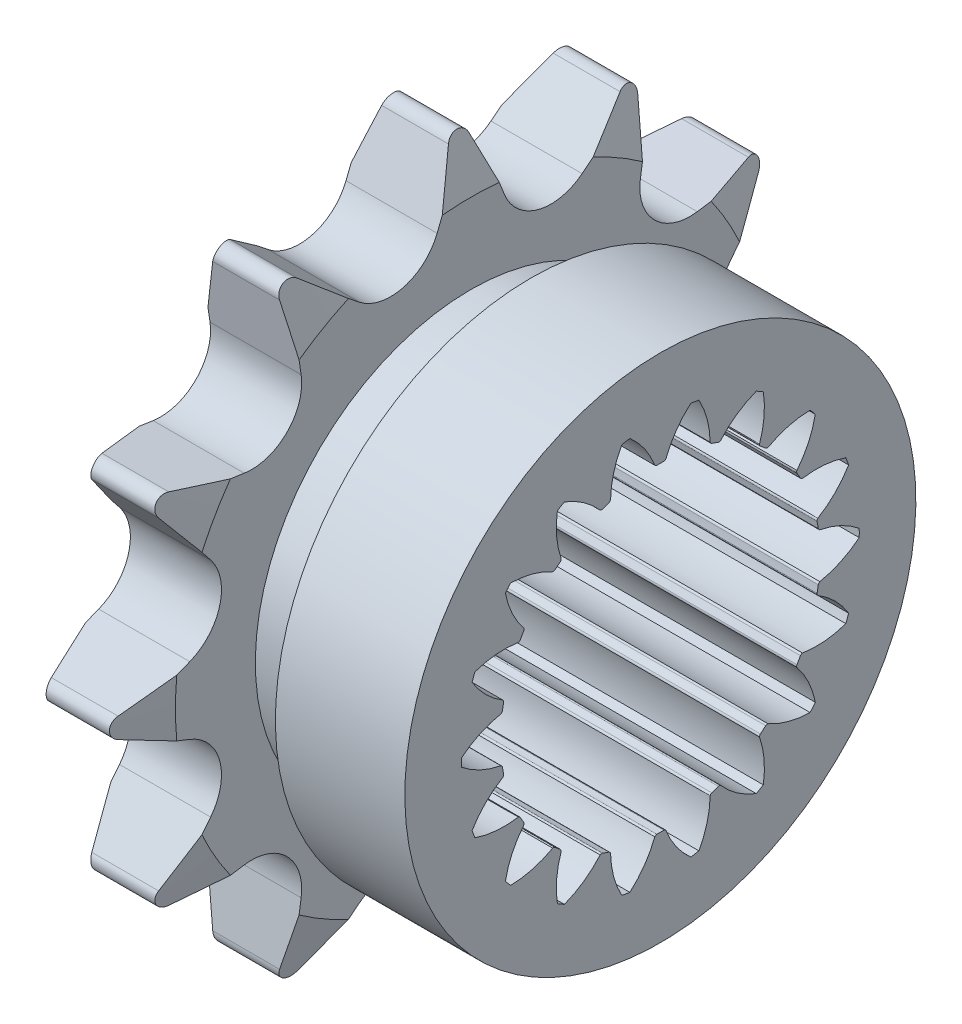
from build123d import *

# Parameters (mm, degrees)
SKETCH13_W         = 22.225
SKETCH13_H         = 27.5082
CUT_EXTRUDE1_DEPTH = 7.2136
CIRPATTERN1_COUNT  = 12
SKETCH15_W         = 127
SKETCH15_H         = 22.5171
SKETCH16_W         = 4.7625
SKETCH16_H         = 3.175
CUT_EXTRUDE2_DEPTH = 23.225


with BuildPart() as part:
    # Sketch13 → Revolve1 (revolve)
    with BuildSketch(Plane.XY):
        with Locations((11.1125, 13.7541)):
            Rectangle(SKETCH13_W, SKETCH13_H)
    revolve(axis=Axis((0, 0, 0), (-1, 0, 0)))

    # Sketch6 → Cut-Extrude1 (cut)
    with BuildSketch(Plane(origin=(0, -16.51, 0), x_dir=(0, 0, -1), z_dir=(1, 0, 0))):
        with BuildLine():
            Line((-0.805715716, 43.469749783), (-2.663822441, 38.756002806))
            ThreePointArc((-2.663822441, 38.756002806), (-5.324614334, 36.381731224), (-8.816063498, 37.107514783))
            Line((-8.816063498, 37.107514783), (-12.782104613, 40.260686049))
            ThreePointArc((-12.782104613, 40.260686049), (-13.256994885, 40.44645554), (-13.7541, 40.332800012))
            ThreePointArc((-13.7541, 40.332800012), (-7.119646056, 43.080880815), (0, 44.0182))
            ThreePointArc((0, 44.0182), (-0.487333422, 43.868076017), (-0.805715716, 43.469749783))
        make_face()
    cut_extrude1 = extrude(amount=CUT_EXTRUDE1_DEPTH, mode=Mode.SUBTRACT)

    # CirPattern1: Cut-Extrude1 ×12 about axis
    cirpattern1_axis = Axis((-63.015770793, 0, 0), (1, 0, 0))
    for i in range(1, CIRPATTERN1_COUNT):
        add(cut_extrude1.rotate(cirpattern1_axis, i * 360 / CIRPATTERN1_COUNT), mode=Mode.SUBTRACT)

    # Sketch15 → hub Cut-Revolve3 (revolve, cut)
    with BuildSketch(Plane.XY):
        with Locations((70.7136, 31.48965)):
            Rectangle(SKETCH15_W, SKETCH15_H)
    revolve(axis=Axis((0, 0, 0), (-1, 0, 0)), mode=Mode.SUBTRACT)

    # Sketch4 → Teeth Chamfer (revolve, cut)
    with BuildSketch(Plane.XY):
        Polygon((0, 27.5082), (1.104501883, 27.5082), (0, 23.386142857), align=None)
        Polygon((7.2136, 27.5082), (6.109098117, 27.5082), (7.2136, 23.386142857), align=None)
    revolve(axis=Axis((0, 0, 0), (-1, 0, 0)), mode=Mode.SUBTRACT)

    # Sketch16 → Recess (revolve, cut)
    with BuildSketch(Plane.XY):
        with Locations((9.59485, 18.6436)):
            Rectangle(SKETCH16_W, SKETCH16_H)
    revolve(axis=Axis((0, 0, 0), (-1, 0, 0)), mode=Mode.SUBTRACT)

    # Sketch36 → Cut-Extrude2 (cut, through all)
    with BuildSketch(Plane.ZY):
        with BuildLine():
            ThreePointArc((-4.7729934, 11.8201419), (-6.061029895, 12.982143528), (-7.592553624, 13.796834183))
            ThreePointArc((-7.592553624, 13.796834183), (-7.873999984, 13.638168068), (-8.152132052, 13.473761428))
            ThreePointArc((-8.152132052, 13.473761428), (-8.212351117, 11.740077645), (-7.850046439, 10.043604504))
            ThreePointArc((-7.850046439, 10.043604504), (-7.86626214, 9.947703548), (-7.918307228, 9.865537551))
            ThreePointArc((-7.918307228, 9.865537551), (-8.13141367, 9.690641477), (-8.340658225, 9.511142985))
            ThreePointArc((-8.340658225, 9.511142985), (-8.430613472, 9.474156555), (-8.527873304, 9.474840233))
            ThreePointArc((-8.527873304, 9.474840233), (-10.135659657, 10.126230162), (-11.853461818, 10.367976993))
            ThreePointArc((-11.853461818, 10.367976993), (-12.063667879, 10.122619291), (-12.268796147, 9.873000815))
            ThreePointArc((-12.268796147, 9.873000815), (-11.732428783, 8.223274824), (-10.811745764, 6.753027031))
            ThreePointArc((-10.811745764, 6.753027031), (-10.794183479, 6.657363513), (-10.814987438, 6.562352263))
            ThreePointArc((-10.814987438, 6.562352263), (-10.95542401, 6.325117018), (-11.090657474, 6.084877757))
            ThreePointArc((-11.090657474, 6.084877757), (-11.162537651, 6.019355375), (-11.254165829, 5.986733001))
            ThreePointArc((-11.254165829, 5.986733001), (-12.987779277, 6.048943991), (-14.684667578, 5.688588763))
            ThreePointArc((-14.684667578, 5.688588763), (-14.798279386, 5.386133234), (-14.905662359, 5.081410594))
            ThreePointArc((-14.905662359, 5.081410594), (-13.837402385, 3.714623697), (-12.469388985, 2.647934833))
            ThreePointArc((-12.469388985, 2.647934833), (-12.420166986, 2.564047187), (-12.407220551, 2.467650443))
            ThreePointArc((-12.407220551, 2.467650443), (-12.458048528, 2.196690097), (-12.50295975, 1.924686467))
            ThreePointArc((-12.50295975, 1.924686467), (-12.548095048, 1.8385311), (-12.623039862, 1.776537414))
            ThreePointArc((-12.623039862, 1.776537414), (-14.273381038, 1.242065902), (-15.744685706, 0.323072774))
            ThreePointArc((-15.744685706, 0.323072774), (-15.748, 1.8e-08), (-15.744685707, -0.323072738))
            ThreePointArc((-15.744685707, -0.323072738), (-14.273381041, -1.24206587), (-12.623039866, -1.776537385))
            ThreePointArc((-12.623039866, -1.776537385), (-12.548095052, -1.838531072), (-12.502959755, -1.924686439))
            ThreePointArc((-12.502959755, -1.924686439), (-12.458048533, -2.196690069), (-12.407220557, -2.467650415))
            ThreePointArc((-12.407220557, -2.467650415), (-12.420166992, -2.564047159), (-12.469388991, -2.647934805))
            ThreePointArc((-12.469388991, -2.647934805), (-13.837402393, -3.714623666), (-14.905662371, -5.08141056))
            ThreePointArc((-14.905662371, -5.08141056), (-14.798279398, -5.3861332), (-14.684667591, -5.68858873))
            ThreePointArc((-14.684667591, -5.68858873), (-12.987779291, -6.048943962), (-11.254165843, -5.986732975))
            ThreePointArc((-11.254165843, -5.986732975), (-11.162537665, -6.01935535), (-11.090657488, -6.084877731))
            ThreePointArc((-11.090657488, -6.084877731), (-10.955424024, -6.325116993), (-10.814987453, -6.562352239))
            ThreePointArc((-10.814987453, -6.562352239), (-10.794183495, -6.657363489), (-10.811745779, -6.753027006))
            ThreePointArc((-10.811745779, -6.753027006), (-11.732428801, -8.223274797), (-12.26879617, -9.873000787))
            ThreePointArc((-12.26879617, -9.873000787), (-12.063667902, -10.122619264), (-11.853461841, -10.367976966))
            ThreePointArc((-11.853461841, -10.367976966), (-10.13565968, -10.126230139), (-8.527873325, -9.474840214))
            ThreePointArc((-8.527873325, -9.474840214), (-8.430613493, -9.474156536), (-8.340658247, -9.511142966))
            ThreePointArc((-8.340658247, -9.511142966), (-8.131413692, -9.690641459), (-7.91830725, -9.865537533))
            ThreePointArc((-7.91830725, -9.865537533), (-7.866262163, -9.94770353), (-7.850046462, -10.043604486))
            ThreePointArc((-7.850046462, -10.043604486), (-8.212351144, -11.740077626), (-8.152132082, -13.473761409))
            ThreePointArc((-8.152132082, -13.473761409), (-7.874000016, -13.63816805), (-7.592553655, -13.796834166))
            ThreePointArc((-7.592553655, -13.796834166), (-6.061029924, -12.982143514), (-4.772993427, -11.820141889))
            ThreePointArc((-4.772993427, -11.820141889), (-4.681832912, -11.78623462), (-4.584652527, -11.79022399))
            ThreePointArc((-4.584652527, -11.79022399), (-4.326634863, -11.887331546), (-4.066562331, -11.9787934))
            ThreePointArc((-4.066562331, -11.9787934), (-3.98955352, -12.038203713), (-3.941515687, -12.122775038))
            ThreePointArc((-3.941515687, -12.122775038), (-3.701742737, -13.840853828), (-3.052200553, -15.449387554))
            ThreePointArc((-3.052200553, -15.449387554), (-2.73461152, -15.508752491), (-2.415871444, -15.561589545))
            ThreePointArc((-2.415871444, -15.561589545), (-1.255350509, -14.272218786), (-0.442420079, -12.739760006))
            ThreePointArc((-0.442420079, -12.739760006), (-0.368354185, -12.676718863), (-0.27567005, -12.647229995))
            ThreePointArc((-0.27567005, -12.647229995), (-1.4e-08, -12.65023401), (0.275670021, -12.647229995))
            ThreePointArc((0.275670021, -12.647229995), (0.368354156, -12.676718864), (0.44242005, -12.739760007))
            ThreePointArc((0.44242005, -12.739760007), (1.255350476, -14.272218789), (2.415871408, -15.561589551))
            ThreePointArc((2.415871408, -15.561589551), (2.734611484, -15.508752498), (3.052200518, -15.449387561))
            ThreePointArc((3.052200518, -15.449387561), (3.701742705, -13.840853836), (3.941515659, -12.122775047))
            ThreePointArc((3.941515659, -12.122775047), (3.989553493, -12.038203723), (4.066562304, -11.978793409))
            ThreePointArc((4.066562304, -11.978793409), (4.326634836, -11.887331556), (4.5846525, -11.790224))
            ThreePointArc((4.5846525, -11.790224), (4.681832885, -11.786234631), (4.7729934, -11.8201419))
            ThreePointArc((4.7729934, -11.8201419), (6.061029895, -12.982143528), (7.592553624, -13.796834183))
            ThreePointArc((7.592553624, -13.796834183), (7.873999984, -13.638168068), (8.152132052, -13.473761428))
            ThreePointArc((8.152132052, -13.473761428), (8.212351117, -11.740077645), (7.850046439, -10.043604504))
            ThreePointArc((7.850046439, -10.043604504), (7.86626214, -9.947703548), (7.918307228, -9.865537551))
            ThreePointArc((7.918307228, -9.865537551), (8.13141367, -9.690641477), (8.340658225, -9.511142985))
            ThreePointArc((8.340658225, -9.511142985), (8.430613472, -9.474156555), (8.527873304, -9.474840233))
            ThreePointArc((8.527873304, -9.474840233), (10.135659657, -10.126230162), (11.853461818, -10.367976993))
            ThreePointArc((11.853461818, -10.367976993), (12.063667879, -10.122619291), (12.268796147, -9.873000815))
            ThreePointArc((12.268796147, -9.873000815), (11.732428783, -8.223274824), (10.811745764, -6.753027031))
            ThreePointArc((10.811745764, -6.753027031), (10.794183479, -6.657363513), (10.814987438, -6.562352263))
            ThreePointArc((10.814987438, -6.562352263), (10.95542401, -6.325117018), (11.090657474, -6.084877757))
            ThreePointArc((11.090657474, -6.084877757), (11.162537651, -6.019355375), (11.254165829, -5.986733001))
            ThreePointArc((11.254165829, -5.986733001), (12.987779277, -6.048943991), (14.684667578, -5.688588763))
            ThreePointArc((14.684667578, -5.688588763), (14.798279386, -5.386133234), (14.905662359, -5.081410594))
            ThreePointArc((14.905662359, -5.081410594), (13.837402385, -3.714623697), (12.469388985, -2.647934833))
            ThreePointArc((12.469388985, -2.647934833), (12.420166986, -2.564047187), (12.407220551, -2.467650443))
            ThreePointArc((12.407220551, -2.467650443), (12.458048528, -2.196690097), (12.50295975, -1.924686467))
            ThreePointArc((12.50295975, -1.924686467), (12.548095048, -1.8385311), (12.623039862, -1.776537414))
            ThreePointArc((12.623039862, -1.776537414), (14.273381038, -1.242065902), (15.744685706, -0.323072774))
            ThreePointArc((15.744685706, -0.323072774), (15.748, -1.8e-08), (15.744685707, 0.323072738))
            ThreePointArc((15.744685707, 0.323072738), (14.273381041, 1.24206587), (12.623039866, 1.776537385))
            ThreePointArc((12.623039866, 1.776537385), (12.548095052, 1.838531072), (12.502959755, 1.924686439))
            ThreePointArc((12.502959755, 1.924686439), (12.458048533, 2.196690069), (12.407220557, 2.467650415))
            ThreePointArc((12.407220557, 2.467650415), (12.420166992, 2.564047159), (12.469388991, 2.647934805))
            ThreePointArc((12.469388991, 2.647934805), (13.837402393, 3.714623666), (14.905662371, 5.08141056))
            ThreePointArc((14.905662371, 5.08141056), (14.798279398, 5.3861332), (14.684667591, 5.68858873))
            ThreePointArc((14.684667591, 5.68858873), (12.987779291, 6.048943962), (11.254165843, 5.986732975))
            ThreePointArc((11.254165843, 5.986732975), (11.162537665, 6.01935535), (11.090657488, 6.084877731))
            ThreePointArc((11.090657488, 6.084877731), (10.955424024, 6.325116993), (10.814987453, 6.562352239))
            ThreePointArc((10.814987453, 6.562352239), (10.794183495, 6.657363489), (10.811745779, 6.753027006))
            ThreePointArc((10.811745779, 6.753027006), (11.732428801, 8.223274797), (12.26879617, 9.873000787))
            ThreePointArc((12.26879617, 9.873000787), (12.063667902, 10.122619264), (11.853461841, 10.367976966))
            ThreePointArc((11.853461841, 10.367976966), (10.13565968, 10.126230139), (8.527873325, 9.474840214))
            ThreePointArc((8.527873325, 9.474840214), (8.430613493, 9.474156536), (8.340658247, 9.511142966))
            ThreePointArc((8.340658247, 9.511142966), (8.131413692, 9.690641459), (7.91830725, 9.865537533))
            ThreePointArc((7.91830725, 9.865537533), (7.866262163, 9.94770353), (7.850046462, 10.043604486))
            ThreePointArc((7.850046462, 10.043604486), (8.212351144, 11.740077626), (8.152132082, 13.473761409))
            ThreePointArc((8.152132082, 13.473761409), (7.874000016, 13.63816805), (7.592553655, 13.796834166))
            ThreePointArc((7.592553655, 13.796834166), (6.061029924, 12.982143514), (4.772993427, 11.820141889))
            ThreePointArc((4.772993427, 11.820141889), (4.681832912, 11.78623462), (4.584652527, 11.79022399))
            ThreePointArc((4.584652527, 11.79022399), (4.326634863, 11.887331546), (4.066562331, 11.9787934))
            ThreePointArc((4.066562331, 11.9787934), (3.98955352, 12.038203713), (3.941515687, 12.122775038))
            ThreePointArc((3.941515687, 12.122775038), (3.701742737, 13.840853828), (3.052200553, 15.449387554))
            ThreePointArc((3.052200553, 15.449387554), (2.73461152, 15.508752491), (2.415871444, 15.561589545))
            ThreePointArc((2.415871444, 15.561589545), (1.255350509, 14.272218786), (0.442420079, 12.739760006))
            ThreePointArc((0.442420079, 12.739760006), (0.368354185, 12.676718863), (0.27567005, 12.647229995))
            ThreePointArc((0.27567005, 12.647229995), (1.4e-08, 12.65023401), (-0.275670021, 12.647229995))
            ThreePointArc((-0.275670021, 12.647229995), (-0.368354156, 12.676718864), (-0.44242005, 12.739760007))
            ThreePointArc((-0.44242005, 12.739760007), (-1.255350476, 14.272218789), (-2.415871408, 15.561589551))
            ThreePointArc((-2.415871408, 15.561589551), (-2.734611484, 15.508752498), (-3.052200518, 15.449387561))
            ThreePointArc((-3.052200518, 15.449387561), (-3.701742705, 13.840853836), (-3.941515659, 12.122775047))
            ThreePointArc((-3.941515659, 12.122775047), (-3.989553493, 12.038203723), (-4.066562304, 11.978793409))
            ThreePointArc((-4.066562304, 11.978793409), (-4.326634836, 11.887331556), (-4.5846525, 11.790224))
            ThreePointArc((-4.5846525, 11.790224), (-4.681832885, 11.786234631), (-4.7729934, 11.8201419))
        make_face()
    extrude(amount=-CUT_EXTRUDE2_DEPTH, mode=Mode.SUBTRACT)


solid = part.part
